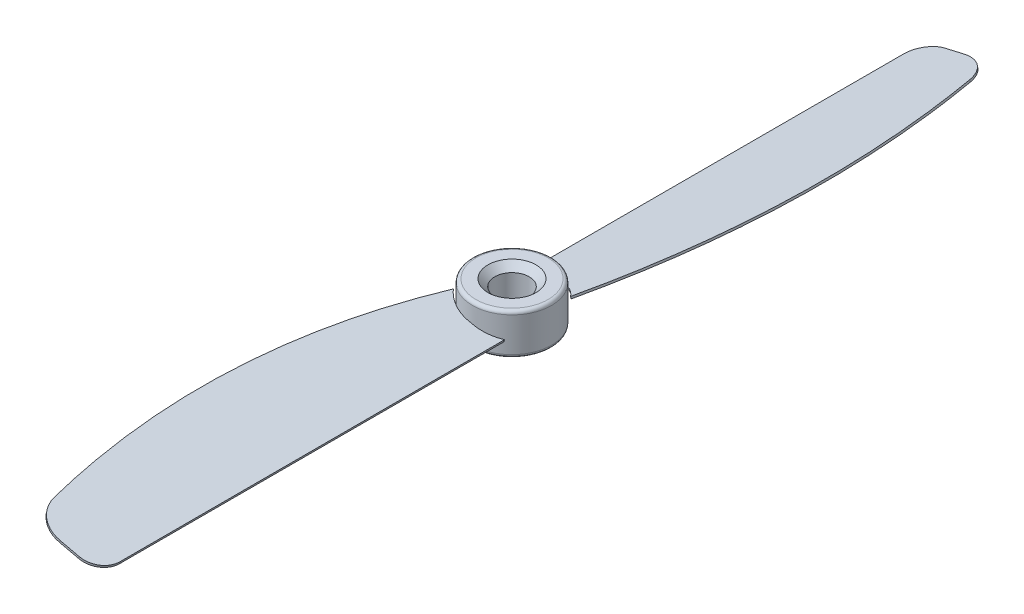
from build123d import *

# Parameters (mm, degrees)
SKETCH1_R           = 5.75
BOSS_EXTRUDE1_DEPTH = 3
BOSS_EXTRUDE2_DEPTH = 0.15
CIRPATTERN1_COUNT   = 2
SKETCH4_R           = 2.5
CUT_EXTRUDE1_DEPTH  = 7.0000001
FILLET1_R           = 0.5
CHAMFER1_SIZE       = 1


with BuildPart() as part:
    # Sketch1 → Boss-Extrude1 (new body, symmetric)
    with BuildSketch(Plane(origin=(0, 0, 0), x_dir=(1, 0, 0), z_dir=(0, 1, 0))):
        Circle(SKETCH1_R)
    extrude(amount=BOSS_EXTRUDE1_DEPTH, both=True)

    # Sketch3 → Boss-Extrude2 (add, symmetric)
    with BuildSketch(Plane(origin=(0, 0, 0), x_dir=(0.974370065, -0.224951054, 0), z_dir=(-0.224951054, -0.974370065, 0))):
        with BuildLine():
            add(Edge.make_bspline(
                [(3.543368809, 3.784271818), (1.869103712, 5.75), (-0.674853163, 5.75)],
                knots=[5.430726938, 5.430726938, 5.430726938, 6.283185307, 6.283185307, 6.283185307], degree=2, weights=[1, 0.910531227, 1]))
            Line((3.543368809, 3.784271818), (3.543368809, 60.5))
            ThreePointArc((3.543368809, 60.5), (2.664689152, 62.621320344), (0.543368809, 63.5))
            Line((0.543368809, 63.5), (-2.327174273, 63.5))
            ThreePointArc((-2.327174273, 63.5), (-5.459156928, 62.397522886), (-7.209963904, 59.576273859))
            add(Edge.make_bspline(
                [(-4.893075135, 3.784271818), (-10.655609146, 21.734523113), (-11.43974903, 40.386779673), (-7.209963904, 59.576273859)],
                knots=[0, 0, 0, 0, 0.936316624, 0.936316624, 0.936316624, 0.936316624], degree=3))
            add(Edge.make_bspline(
                [(-0.674853163, 5.75), (-3.218810038, 5.75), (-4.893075135, 3.784271818)],
                knots=[0, 0, 0, 0.852458369, 0.852458369, 0.852458369], degree=2, weights=[1, 0.910531227, 1]))
        make_face()
    boss_extrude2 = extrude(amount=BOSS_EXTRUDE2_DEPTH, both=True)

    # CirPattern1: Boss-Extrude2 ×2 about axis
    cirpattern1_axis = Axis((0, 3, 0), (0, -1, 0))
    for i in range(1, CIRPATTERN1_COUNT):
        add(boss_extrude2.rotate(cirpattern1_axis, i * 360 / CIRPATTERN1_COUNT))

    # Sketch4 → Cut-Extrude1 (cut, through all)
    with BuildSketch(Plane(origin=(0, 3, 0), x_dir=(1, 0, 0), z_dir=(0, 1, 0))):
        Circle(SKETCH4_R)
    extrude(amount=-CUT_EXTRUDE1_DEPTH, mode=Mode.SUBTRACT)

    # Fillet1
    fillet1_edges = [part.edges().sort_by_distance(p)[0] for p in [
        (-5.75, -3, 0),
        (-5.75, 3, 0),
    ]]
    fillet(fillet1_edges, radius=FILLET1_R)

    # Chamfer1
    chamfer1_edges = [part.edges().sort_by_distance(p)[0] for p in [
        (-2.5, -3, 0),
        (-2.5, 3, 0),
    ]]
    chamfer(chamfer1_edges, length=CHAMFER1_SIZE)


solid = part.part
